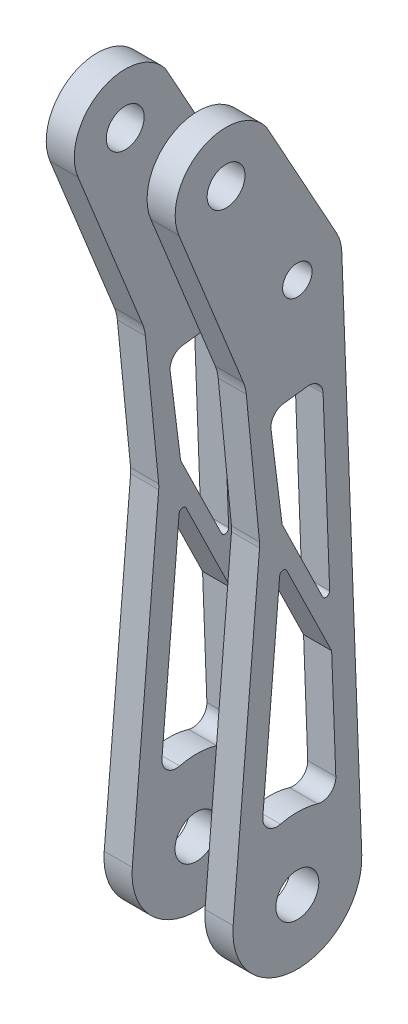
from build123d import *

# Parameters (mm, degrees)
SKETCH6_R           = 3.2639
SKETCH6_R_2         = 4.19989
BOSS_EXTRUDE3_DEPTH = 14.2875
SKETCH7_R           = 4.7625
CUT_EXTRUDE1_DEPTH  = 7.14375
SKETCH8_R           = 7.9375
CUT_EXTRUDE2_DEPTH  = 5.55625
CUT_EXTRUDE3_DEPTH  = 29.21
CUT_EXTRUDE5_DEPTH  = 28.575
FILLET2_R           = 3.175
FILLET3_R           = 3.175
BOSS_EXTRUDE4_DEPTH = 6.223
FILLET4_R           = 0.8255
BOSS_EXTRUDE5_DEPTH = 6.223
FILLET6_R           = 0.8255


with BuildPart() as part:
    # Sketch6 → Boss-Extrude3 (new body, symmetric)
    with BuildSketch(Plane(origin=(0, 0, 0), x_dir=(0, 0, -1), z_dir=(1, 0, 0))):
        with BuildLine():
            Line((-8.381868112, 70.779690611), (-14.237180291, 1.198062439))
            ThreePointArc((-14.237180291, 1.198062439), (-0.331752192, -14.283647879), (14.277450567, 0.53578125))
            Line((14.277450567, 0.53578125), (11.553393182, 73.126217476))
            Line((11.553393182, 73.126217476), (9.854739755, 118.39178125))
            ThreePointArc((9.854739755, 118.39178125), (9.530289118, 120.556972634), (8.73611616, 122.597220477))
            Line((8.73611616, 122.597220477), (-6.910022509, 150.896463863))
            ThreePointArc((-6.910022509, 150.896463863), (-21.450180104, 153.711509321), (-26.264611031, 139.705727705))
            Line((-26.264611031, 139.705727705), (-11.969665934, 104.365862186))
            ThreePointArc((-11.969665934, 104.365862186), (-11.552306922, 103.075438538), (-11.323296274, 101.738675336))
            Line((-11.323296274, 101.738675336), (-8.390034626, 71.934102831))
            ThreePointArc((-8.390034626, 71.934102831), (-8.359662681, 71.357082692), (-8.381868112, 70.779690611))
        make_face()
        with Locations((0, 118.021968393)):
            Circle(SKETCH6_R, mode=Mode.SUBTRACT)
        with Locations((-15.799642553, 143.938798421)):
            Circle(SKETCH6_R_2, mode=Mode.SUBTRACT)
    extrude(amount=BOSS_EXTRUDE3_DEPTH, both=True)

    # Sketch7 → Cut-Extrude1 (cut)
    with BuildSketch(Plane(origin=(14.2875, 0, 0), x_dir=(0, 0, -1), z_dir=(1, 0, 0))):
        Circle(SKETCH7_R)
    cut_extrude1 = extrude(amount=-CUT_EXTRUDE1_DEPTH, mode=Mode.SUBTRACT)

    # Sketch8 → Cut-Extrude2 (cut)
    with BuildSketch(Plane(origin=(7.14375, 0, 0), x_dir=(0, 0, -1), z_dir=(1, 0, 0))):
        Circle(SKETCH8_R)
    cut_extrude2 = extrude(amount=-CUT_EXTRUDE2_DEPTH, mode=Mode.SUBTRACT)

    # Mirror1: Cut-Extrude2 across plane
    add(cut_extrude2.mirror(Plane(origin=(0, 0, 0), x_dir=(0, 0, 1), z_dir=(1, 0, 0))), mode=Mode.SUBTRACT)

    # Mirror2: Cut-Extrude1 across plane
    add(cut_extrude1.mirror(Plane(origin=(0, 0, 0), x_dir=(0, 0, 1), z_dir=(1, 0, 0))), mode=Mode.SUBTRACT)

    # Sketch10 → Cut-Extrude3 (cut, symmetric)
    with BuildSketch(Plane(origin=(0, 0, 14.237180291), x_dir=(-1, 0, 0), z_dir=(0, 0, -1))):
        with BuildLine():
            Line((-8.0645, 155.976463863), (-8.0645, -18.648536137))
            ThreePointArc((-8.0645, -18.648536137), (-7.13456403, -20.893600167), (-4.8895, -21.823536137))
            Line((-4.8895, -21.823536137), (4.8895, -21.823536137))
            ThreePointArc((4.8895, -21.823536137), (7.13456403, -20.893600167), (8.0645, -18.648536137))
            Line((8.0645, -18.648536137), (8.0645, 155.976463863))
            Line((8.0645, 155.976463863), (-8.0645, 155.976463863))
        make_face()
    extrude(amount=CUT_EXTRUDE3_DEPTH, both=True, mode=Mode.SUBTRACT)

    # Sketch13 → Cut-Extrude5 (cut)
    with BuildSketch(Plane(origin=(14.2875, 0, 0), x_dir=(0, 0, -1), z_dir=(1, 0, 0))):
        with BuildLine():
            Line((-3.369379853, 72.742718267), (-6.230490775, 95.422966156))
            Line((-6.230490775, 95.422966156), (5.577203891, 96.912505615))
            Line((5.577203891, 96.912505615), (8.716072329, 13.26822174))
            ThreePointArc((8.716072329, 13.26822174), (0.368613547, 15.870719866), (-8.090670188, 13.658575362))
            Line((-8.090670188, 13.658575362), (-3.319759564, 70.353712855))
            ThreePointArc((-3.319759564, 70.353712855), (-3.281968474, 71.549515806), (-3.369379853, 72.742718267))
        make_face()
    extrude(amount=-CUT_EXTRUDE5_DEPTH, mode=Mode.SUBTRACT)

    # Fillet2
    fillet2_edges = [part.edges().sort_by_distance(p)[0] for p in [
        (-11.176, 95.422966156, 6.230490775),
        (-11.176, 96.912505615, -5.577203891),
        (-11.176, 13.26822174, -8.716072329),
        (-11.176, 13.658575362, 8.090670188),
    ]]
    fillet(fillet2_edges, radius=FILLET2_R)

    # Fillet3
    fillet3_edges = [part.edges().sort_by_distance(p)[0] for p in [
        (11.176, 95.422966156, 6.230490775),
        (11.176, 96.912505615, -5.577203891),
        (11.176, 13.26822174, -8.716072329),
        (11.176, 13.658575362, 8.090670188),
    ]]
    fillet(fillet3_edges, radius=FILLET3_R)

    # Sketch21 → Boss-Extrude4 (add)
    with BuildSketch(Plane(origin=(14.2875, 0, 0), x_dir=(0, 0, -1), z_dir=(1, 0, 0))):
        with BuildLine():
            Line((-3.369379853, 72.742718267), (7.304454361, 50.884890412))
            Line((7.304454361, 50.884890412), (7.59858159, 43.047014467))
            Line((7.59858159, 43.047014467), (-3.674943248, 66.132885981))
            Line((-3.674943248, 66.132885981), (-3.319759564, 70.353712855))
            ThreePointArc((-3.319759564, 70.353712855), (-3.281968474, 71.549515806), (-3.369379853, 72.742718267))
        make_face()
    extrude(amount=-BOSS_EXTRUDE4_DEPTH)

    # Fillet4
    fillet4_edges = [part.edges().sort_by_distance(p)[0] for p in [
        (11.176, 66.132885981, 3.674943248),
        (11.176, 50.884890412, -7.304454361),
    ]]
    fillet(fillet4_edges, radius=FILLET4_R)

    # Sketch23 → Boss-Extrude5 (add)
    with BuildSketch(Plane(origin=(-14.2875, 0, -12.7), x_dir=(0, 0, -1), z_dir=(1, 0, 0))):
        with BuildLine():
            Line((-16.361406478, 74.242085268), (-5.432185966, 51.861278542))
            Line((-5.432185966, 51.861278542), (-5.138058737, 44.023402597))
            Line((-5.138058737, 44.023402597), (-16.310243165, 66.901749696))
            Line((-16.310243165, 66.901749696), (-16.019759564, 70.353712855))
            ThreePointArc((-16.019759564, 70.353712855), (-16.023369976, 72.312591024), (-16.361406478, 74.242085268))
        make_face()
    extrude(amount=BOSS_EXTRUDE5_DEPTH)

    # Fillet6
    fillet6_edges = [part.edges().sort_by_distance(p)[0] for p in [
        (-11.176, 66.901749696, 3.610243165),
        (-11.176, 51.861278542, -7.267814034),
    ]]
    fillet(fillet6_edges, radius=FILLET6_R)


solid = part.part
